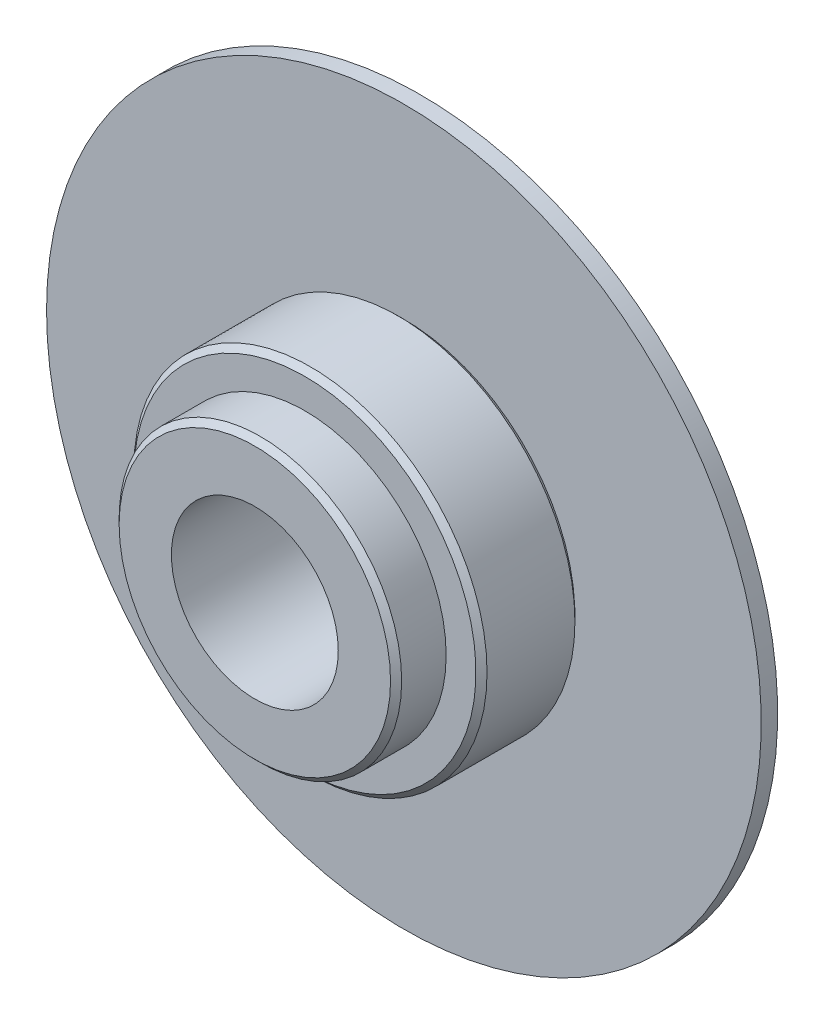
from build123d import *

# Parameters (mm, degrees)
SKETCH1_R           = 5.08
BOSS_EXTRUDE1_DEPTH = 1.8
SKETCH2_R           = 6.35
BOSS_EXTRUDE2_DEPTH = 3.56
CHAMFER1_SIZE       = 0.2
SKETCH3_R           = 12.85
BOSS_EXTRUDE3_DEPTH = 0.59
SKETCH4_R           = 5
BOSS_EXTRUDE4_DEPTH = 0.5
SKETCH5_R           = 3
CUT_EXTRUDE1_DEPTH  = 7.45


with BuildPart() as part:
    # Sketch1 → Boss-Extrude1 (new body)
    with BuildSketch(Plane.XY):
        Circle(SKETCH1_R)
    extrude(amount=-BOSS_EXTRUDE1_DEPTH)

    # Sketch2 → Boss-Extrude2 (add)
    with BuildSketch(Plane(origin=(0, 0, -1.8), x_dir=(-1, 0, 0), z_dir=(0, 0, -1))):
        Circle(SKETCH2_R)
    extrude(amount=BOSS_EXTRUDE2_DEPTH)

    # Chamfer1
    chamfer1_edges = [part.edges().sort_by_distance(p)[0] for p in [
        (-5.08, 0, 0),
        (6.35, 0, -1.8),
        (6.35, 0, -5.36),
    ]]
    chamfer(chamfer1_edges, length=CHAMFER1_SIZE)

    # Sketch3 → Boss-Extrude3 (add)
    with BuildSketch(Plane(origin=(0, 0, -5.36), x_dir=(-1, 0, 0), z_dir=(0, 0, -1))):
        Circle(SKETCH3_R)
    extrude(amount=BOSS_EXTRUDE3_DEPTH)

    # Sketch4 → Boss-Extrude4 (add)
    with BuildSketch(Plane(origin=(0, 0, -5.95), x_dir=(-1, 0, 0), z_dir=(0, 0, -1))):
        Circle(SKETCH4_R)
    extrude(amount=BOSS_EXTRUDE4_DEPTH)

    # Sketch5 → Cut-Extrude1 (cut, through all)
    with BuildSketch(Plane.XY):
        Circle(SKETCH5_R)
    extrude(amount=-CUT_EXTRUDE1_DEPTH, mode=Mode.SUBTRACT)


solid = part.part
